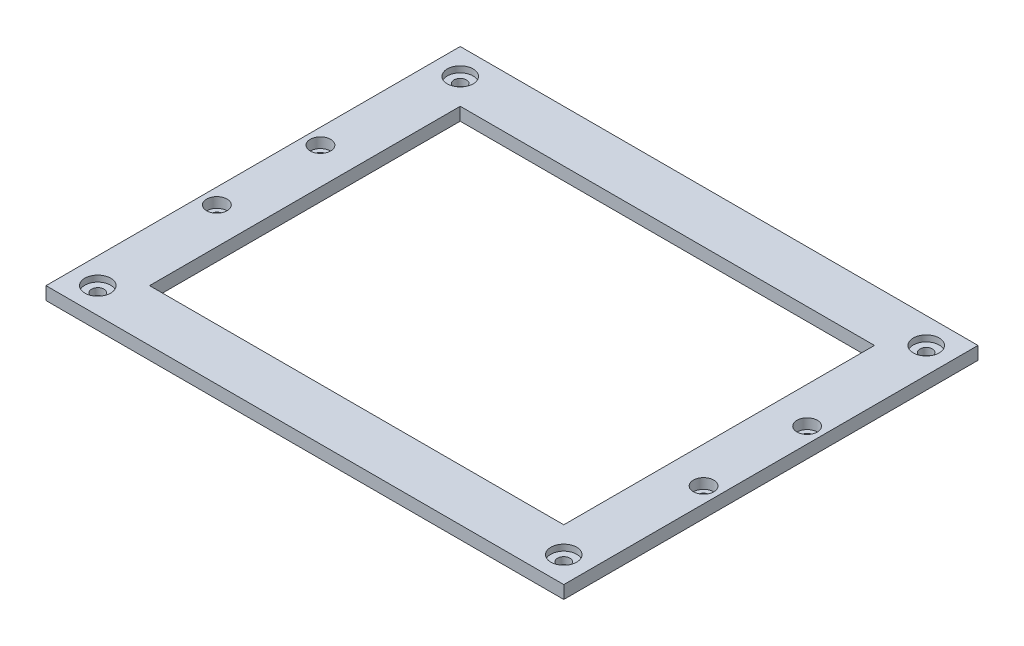
from build123d import *

# Parameters (mm, degrees)
SKETCH1_W                      = 254
SKETCH1_H                      = 203.2
SKETCH1_R                      = 3.05
SKETCH1_W_2                    = 203.2
SKETCH1_H_2                    = 152.4
BOSS_EXTRUDE1_DEPTH            = 6.35
SKETCH2_R                      = 6.35
CUT_EXTRUDE1_DEPTH             = 3
CBORE_FOR_M5_SHCS1_D           = 5.5
CBORE_FOR_M5_SHCS1_CBORE_D     = 10
CBORE_FOR_M5_SHCS1_CBORE_DEPTH = 5


with BuildPart() as part:
    # Sketch1 → Boss-Extrude1 (new body)
    with BuildSketch(Plane(origin=(0, 0, 0), x_dir=(1, 0, 0), z_dir=(0, 1, 0))):
        with Locations((127, 101.6)):
            Rectangle(SKETCH1_W, SKETCH1_H)
        with Locations((12.7, 190.5)):
            Circle(SKETCH1_R, mode=Mode.SUBTRACT)
        with Locations((241.3, 190.5)):
            Circle(SKETCH1_R, mode=Mode.SUBTRACT)
        with Locations((241.3, 12.7)):
            Circle(SKETCH1_R, mode=Mode.SUBTRACT)
        with Locations((12.7, 12.7)):
            Circle(SKETCH1_R, mode=Mode.SUBTRACT)
        with Locations((127, 101.6)):
            Rectangle(SKETCH1_W_2, SKETCH1_H_2, mode=Mode.SUBTRACT)
    extrude(amount=BOSS_EXTRUDE1_DEPTH)

    # Sketch2 → Cut-Extrude1 (cut)
    with BuildSketch(Plane(origin=(0, 6.35, 0), x_dir=(1, 0, 0), z_dir=(0, 1, 0))):
        with Locations((12.7, 190.5)):
            Circle(SKETCH2_R)
        with Locations((241.3, 190.5)):
            Circle(SKETCH2_R)
        with Locations((241.3, 12.7)):
            Circle(SKETCH2_R)
        with Locations((12.7, 12.7)):
            Circle(SKETCH2_R)
    extrude(amount=-CUT_EXTRUDE1_DEPTH, mode=Mode.SUBTRACT)

    # CBORE for M5 SHCS1 (through all)
    with Locations(Plane(origin=(0, 6.35, 0), x_dir=(1, 0, 0), z_dir=(0, 1, 0))):
        with Locations((246.38, 76.2), (246.38, 127), (7.62, 76.2), (7.62, 127)):
            CounterBoreHole(CBORE_FOR_M5_SHCS1_D / 2, CBORE_FOR_M5_SHCS1_CBORE_D / 2, CBORE_FOR_M5_SHCS1_CBORE_DEPTH)


solid = part.part
